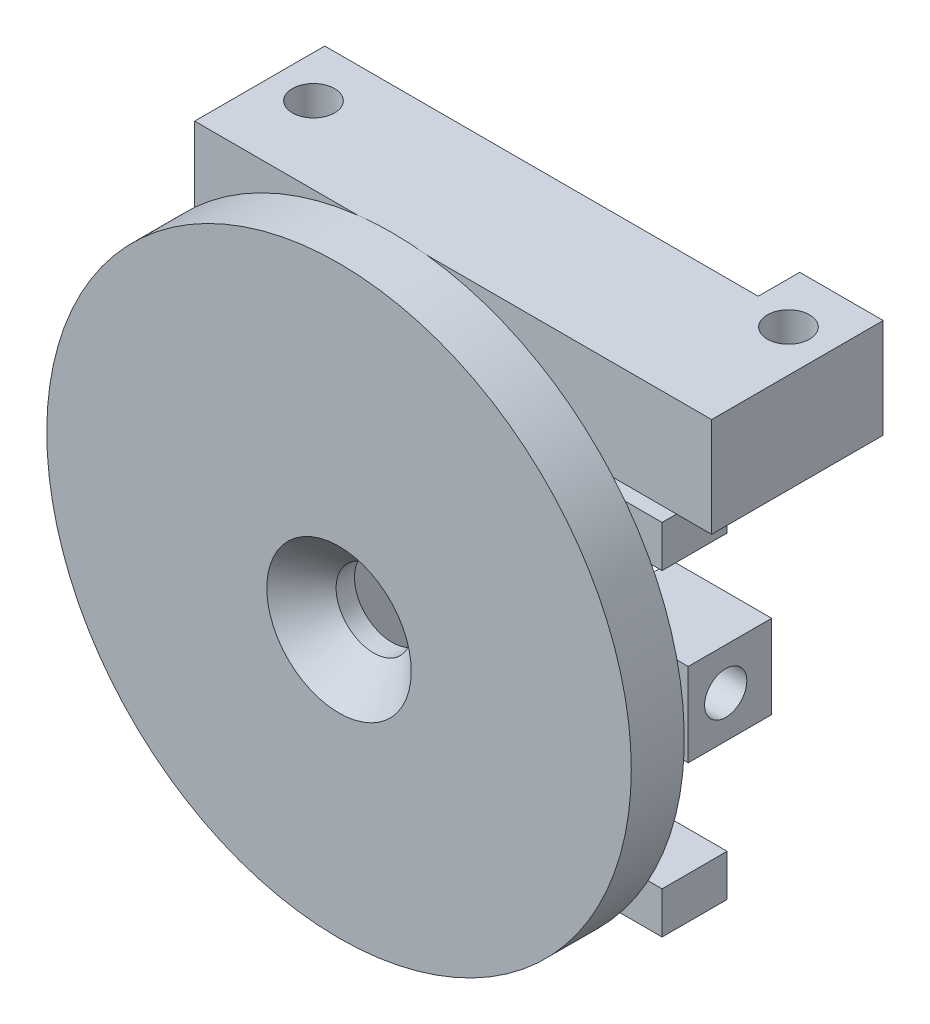
from build123d import *

# Parameters (mm, degrees)
SKETCH1_R                                       = 35
BOSS_EXTRUDE1_DEPTH                             = 6.35
SKETCH2_W                                       = 25.4
SKETCH2_H                                       = 69.5
SKETCH2_W_2                                     = 14.7
SKETCH2_H_2                                     = 52.8
BOSS_EXTRUDE2_DEPTH                             = 15.578435
CSK_FOR_M8_FLAT_HEAD_MACHINE_SCREW1_D           = 9
CSK_FOR_M8_FLAT_HEAD_MACHINE_SCREW1_DEPTH       = 17.5
CSK_FOR_M8_FLAT_HEAD_MACHINE_SCREW1_CSINK_D     = 17.3
CSK_FOR_M8_FLAT_HEAD_MACHINE_SCREW1_CSINK_ANGLE = 90
CSK_FOR_M8_FLAT_HEAD_MACHINE_SCREW1_TIP         = 2.703872786
SKETCH6_W                                       = 15.578435
SKETCH6_H                                       = 11.9
BOSS_EXTRUDE3_DEPTH                             = 25.572145
SKETCH7_W                                       = 15.578435
SKETCH7_H                                       = 11.9
BOSS_EXTRUDE4_DEPTH                             = 10.937286
SKETCH8_R                                       = 2.5273
CUT_EXTRUDE1_DEPTH                              = 7
SKETCH9_W                                       = 10
SKETCH9_H                                       = 11.9
BOSS_EXTRUDE5_DEPTH                             = 4.972688
SKETCH10_R                                      = 2.5273
CUT_EXTRUDE2_DEPTH                              = 7
SKETCH11_W                                      = 5.3384196
SKETCH11_H                                      = 10
BOSS_EXTRUDE6_DEPTH                             = 5.35
SKETCH12_W                                      = 10
SKETCH12_H                                      = 10
SKETCH12_W_2                                    = 7.789222
SKETCH12_H_2                                    = 5
BOSS_EXTRUDE7_DEPTH                             = 11.85
SKETCH13_R                                      = 2.5273
CUT_EXTRUDE3_DEPTH                              = 7
SKETCH14_W                                      = 5.35
SKETCH14_H                                      = 10
CUT_EXTRUDE4_DEPTH                              = 5.33842


with BuildPart() as part:
    # Sketch1 → Boss-Extrude1 (new body)
    with BuildSketch(Plane.XY):
        Circle(SKETCH1_R)
    extrude(amount=BOSS_EXTRUDE1_DEPTH)

    # Sketch2 → Boss-Extrude2 (add)
    with BuildSketch(Plane(origin=(0, 0, 0), x_dir=(-1, 0, 0), z_dir=(0, 0, -1))):
        Rectangle(SKETCH2_W, SKETCH2_H)
        with Locations((0, -3)):
            Rectangle(SKETCH2_W_2, SKETCH2_H_2, mode=Mode.SUBTRACT)
    extrude(amount=BOSS_EXTRUDE2_DEPTH)

    # CSK for M8 Flat Head Machine Screw1
    with Locations(Plane.XY.offset(6.35)):
        with Locations((0, -3)):
            CounterSinkHole(CSK_FOR_M8_FLAT_HEAD_MACHINE_SCREW1_D / 2, CSK_FOR_M8_FLAT_HEAD_MACHINE_SCREW1_CSINK_D / 2, depth=CSK_FOR_M8_FLAT_HEAD_MACHINE_SCREW1_DEPTH, counter_sink_angle=CSK_FOR_M8_FLAT_HEAD_MACHINE_SCREW1_CSINK_ANGLE)
            with Locations((0, 0, -(CSK_FOR_M8_FLAT_HEAD_MACHINE_SCREW1_DEPTH + CSK_FOR_M8_FLAT_HEAD_MACHINE_SCREW1_TIP / 2))):  # 118° drill point
                Cone(0, CSK_FOR_M8_FLAT_HEAD_MACHINE_SCREW1_D / 2, CSK_FOR_M8_FLAT_HEAD_MACHINE_SCREW1_TIP, mode=Mode.SUBTRACT)

    # Sketch6 → Boss-Extrude3 (add)
    with BuildSketch(Plane(origin=(12.7, 0, 0), x_dir=(0, 0, -1), z_dir=(1, 0, 0))):
        with Locations((7.7892175, 28.8)):
            Rectangle(SKETCH6_W, SKETCH6_H)
    extrude(amount=BOSS_EXTRUDE3_DEPTH)

    # Sketch7 → Boss-Extrude4 (add)
    with BuildSketch(Plane.ZY.offset(12.7)):
        with Locations((-7.7892175, 28.8)):
            Rectangle(SKETCH7_W, SKETCH7_H)
    extrude(amount=BOSS_EXTRUDE4_DEPTH)

    # Sketch8 → Cut-Extrude1 (cut)
    with BuildSketch(Plane(origin=(0, 34.75, 0), x_dir=(1, 0, 0), z_dir=(0, 1, 0))):
        with Locations((-18.637286, 9.228435)):
            Circle(SKETCH8_R)
    extrude(amount=-CUT_EXTRUDE1_DEPTH, mode=Mode.SUBTRACT)

    # Sketch9 → Boss-Extrude5 (add)
    with BuildSketch(Plane(origin=(0, 0, -15.578435), x_dir=(-1, 0, 0), z_dir=(0, 0, -1))):
        with Locations((-33.272145, 28.8)):
            Rectangle(SKETCH9_W, SKETCH9_H)
    extrude(amount=BOSS_EXTRUDE5_DEPTH)

    # Sketch10 → Cut-Extrude2 (cut)
    with BuildSketch(Plane(origin=(0, 34.75, 0), x_dir=(1, 0, 0), z_dir=(0, 1, 0))):
        with Locations((33.272145, 14.201123)):
            Circle(SKETCH10_R)
    extrude(amount=-CUT_EXTRUDE2_DEPTH, mode=Mode.SUBTRACT)

    # Sketch11 → Boss-Extrude6 (add)
    with BuildSketch(Plane(origin=(12.7, 0, 0), x_dir=(0, 0, -1), z_dir=(1, 0, 0))):
        with Locations((18.2476448, -8.175)):
            Rectangle(SKETCH11_W, SKETCH11_H)
    extrude(amount=-BOSS_EXTRUDE6_DEPTH)

    # Sketch12 → Boss-Extrude7 (add)
    with BuildSketch(Plane(origin=(12.7, 0, 0), x_dir=(0, 0, -1), z_dir=(1, 0, 0))):
        with Locations((15.9168546, -8.175)):
            Rectangle(SKETCH12_W, SKETCH12_H)
        with Locations((11.683824, 10.825)):
            Rectangle(SKETCH12_W_2, SKETCH12_H_2)
        with Locations((11.683824, -27.175)):
            Rectangle(SKETCH12_W_2, SKETCH12_H_2)
    extrude(amount=BOSS_EXTRUDE7_DEPTH)

    # Sketch13 → Cut-Extrude3 (cut)
    with BuildSketch(Plane(origin=(24.55, 0, 0), x_dir=(0, 0, -1), z_dir=(1, 0, 0))):
        with Locations((15.4092126, -8.175)):
            Circle(SKETCH13_R)
    extrude(amount=-CUT_EXTRUDE3_DEPTH, mode=Mode.SUBTRACT)

    # Sketch14 → Cut-Extrude4 (cut)
    with BuildSketch(Plane(origin=(0, 0, -20.9168546), x_dir=(-1, 0, 0), z_dir=(0, 0, -1))):
        with Locations((-10.025, -8.175)):
            Rectangle(SKETCH14_W, SKETCH14_H)
    extrude(amount=-CUT_EXTRUDE4_DEPTH, mode=Mode.SUBTRACT)


solid = part.part
